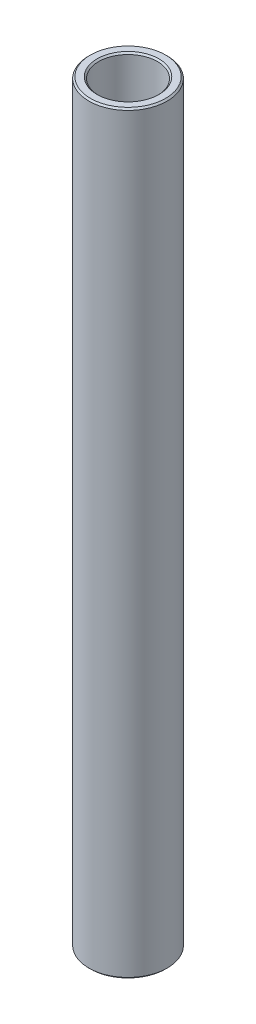
from build123d import *

# Parameters (mm, degrees)
SKETCH1_W     = 1.5875
SKETCH1_H     = 122.2375
CHAMFER1_SIZE = 0.254


with BuildPart() as part:
    # Sketch1 → Revolve1 (revolve)
    with BuildSketch(Plane.XY):
        with Locations((5.55625, 192.88113993)):
            Rectangle(SKETCH1_W, SKETCH1_H)
    revolve(axis=Axis((0, 122.23738993, 0), (0, 1, 0)))

    # Chamfer1
    chamfer1_edges = [part.edges().sort_by_distance(p)[0] for p in [
        (-6.35, 131.76238993, 0),
        (-6.35, 253.99988993, 0),
        (-4.7625, 253.99988993, 0),
        (-4.7625, 131.76238993, 0),
    ]]
    chamfer(chamfer1_edges, length=CHAMFER1_SIZE)


solid = part.part
